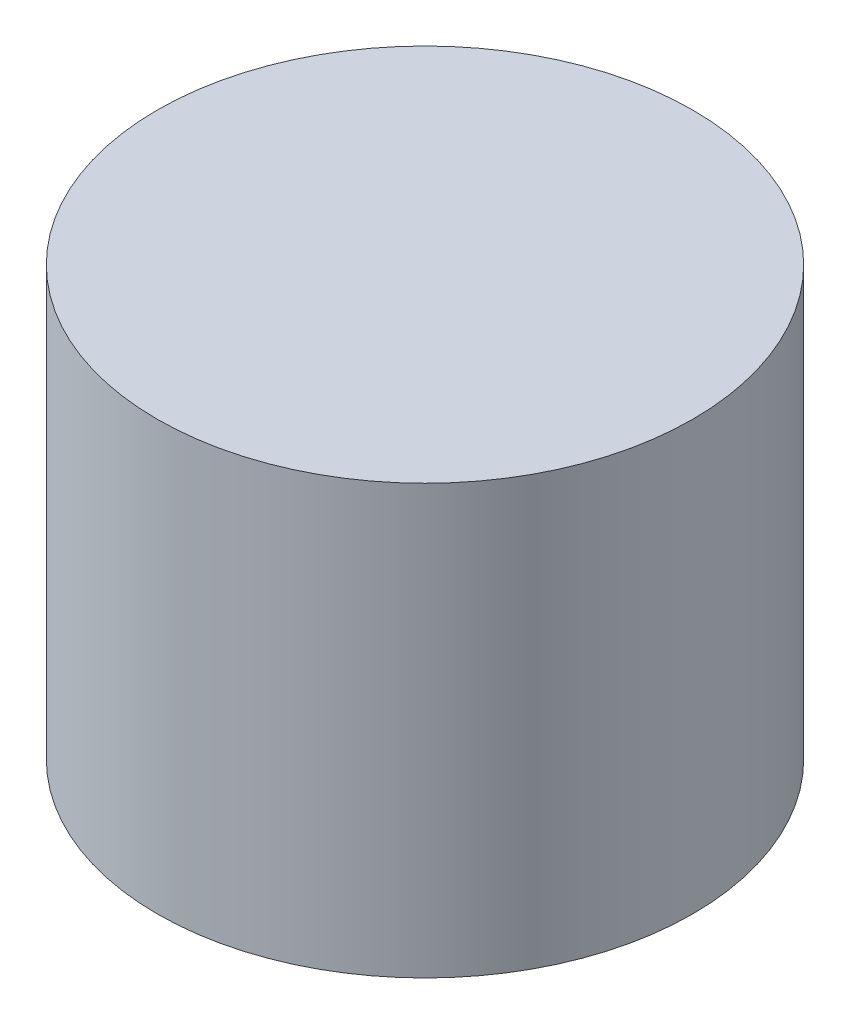
from build123d import *

# Parameters (mm, degrees)
SKETCH1_R           = 12.5
BOSS_EXTRUDE1_DEPTH = 20


with BuildPart() as part:
    # Sketch1 → Boss-Extrude1 (new body)
    with BuildSketch(Plane(origin=(0, 0, 0), x_dir=(1, 0, 0), z_dir=(0, 1, 0))):
        Circle(SKETCH1_R)
    extrude(amount=BOSS_EXTRUDE1_DEPTH)


solid = part.part
